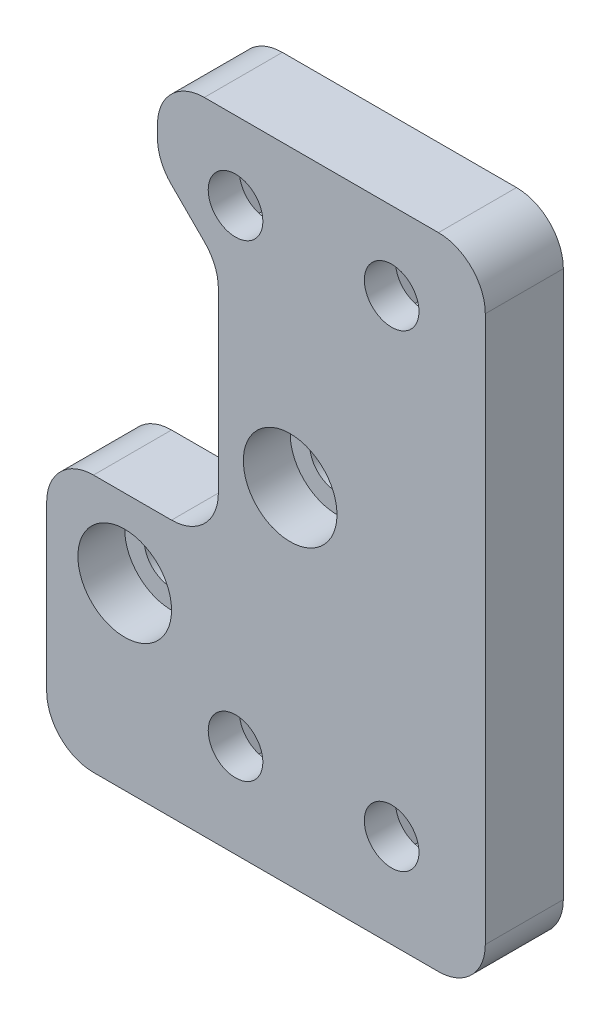
from build123d import *

# Parameters (mm, degrees)
SKETCH2_R           = 1.75
BOSS_EXTRUDE1_DEPTH = 5
SKETCH3_R           = 3
CUT_EXTRUDE1_DEPTH  = 3
FILLET1_R           = 3
CUT_EXTRUDE2_DEPTH  = 3


with BuildPart() as part:
    # Sketch2 → Boss-Extrude1 (new body)
    with BuildSketch(Plane.XY):
        Polygon((11, -21), (11, 20), (-10, 20), (-10, 15), (-6.1, 11.1), (-6.1, -4.5), (-17.1, -4.5), (-17.1, -21), align=None)
        with Locations((-1.5, 1.1)):
            Circle(SKETCH2_R, mode=Mode.SUBTRACT)
        with Locations((-12.1, -9.5)):
            Circle(SKETCH2_R, mode=Mode.SUBTRACT)
        with Locations((-5, 15)):
            Circle(SKETCH2_R, mode=Mode.SUBTRACT)
        with Locations((-5, -15)):
            Circle(SKETCH2_R, mode=Mode.SUBTRACT)
        with Locations((5, 15)):
            Circle(SKETCH2_R, mode=Mode.SUBTRACT)
        with Locations((5, -15)):
            Circle(SKETCH2_R, mode=Mode.SUBTRACT)
    extrude(amount=BOSS_EXTRUDE1_DEPTH)

    # Sketch3 → Cut-Extrude1 (cut)
    with BuildSketch(Plane.XY.offset(5)):
        with Locations((-1.5, 1.1)):
            Circle(SKETCH3_R)
        with Locations((-12.1, -9.5)):
            Circle(SKETCH3_R)
    extrude(amount=-CUT_EXTRUDE1_DEPTH, mode=Mode.SUBTRACT)

    # Fillet1
    fillet1_edges = [part.edges().sort_by_distance(p)[0] for p in [
        (-6.1, -4.5, 2.5),
        (-6.1, 11.1, 2.5),
        (-10, 15, 2.5),
        (-10, 20, 2.5),
        (11, 20, 2.5),
        (11, -21, 2.5),
        (-17.1, -21, 2.5),
        (-17.1, -4.5, 2.5),
    ]]
    fillet(fillet1_edges, radius=FILLET1_R)

    # Sketch4 → Cut-Extrude2 (cut)
    with BuildSketch(Plane(origin=(0, 0, 0), x_dir=(-1, 0, 0), z_dir=(0, 0, -1))):
        Polygon((-3.383419246, 12.2), (-1.766838493, 15), (-3.383419246, 17.8), (-6.616580754, 17.8), (-8.233161507, 15), (-6.616580754, 12.2), align=None)
        Polygon((6.616580754, 12.2), (8.233161507, 15), (6.616580754, 17.8), (3.383419246, 17.8), (1.766838493, 15), (3.383419246, 12.2), align=None)
        Polygon((-3.383419246, -17.8), (-1.766838493, -15), (-3.383419246, -12.2), (-6.616580754, -12.2), (-8.233161507, -15), (-6.616580754, -17.8), align=None)
        Polygon((6.616580754, -17.8), (8.233161507, -15), (6.616580754, -12.2), (3.383419246, -12.2), (1.766838493, -15), (3.383419246, -17.8), align=None)
    extrude(amount=-CUT_EXTRUDE2_DEPTH, mode=Mode.SUBTRACT)


solid = part.part
